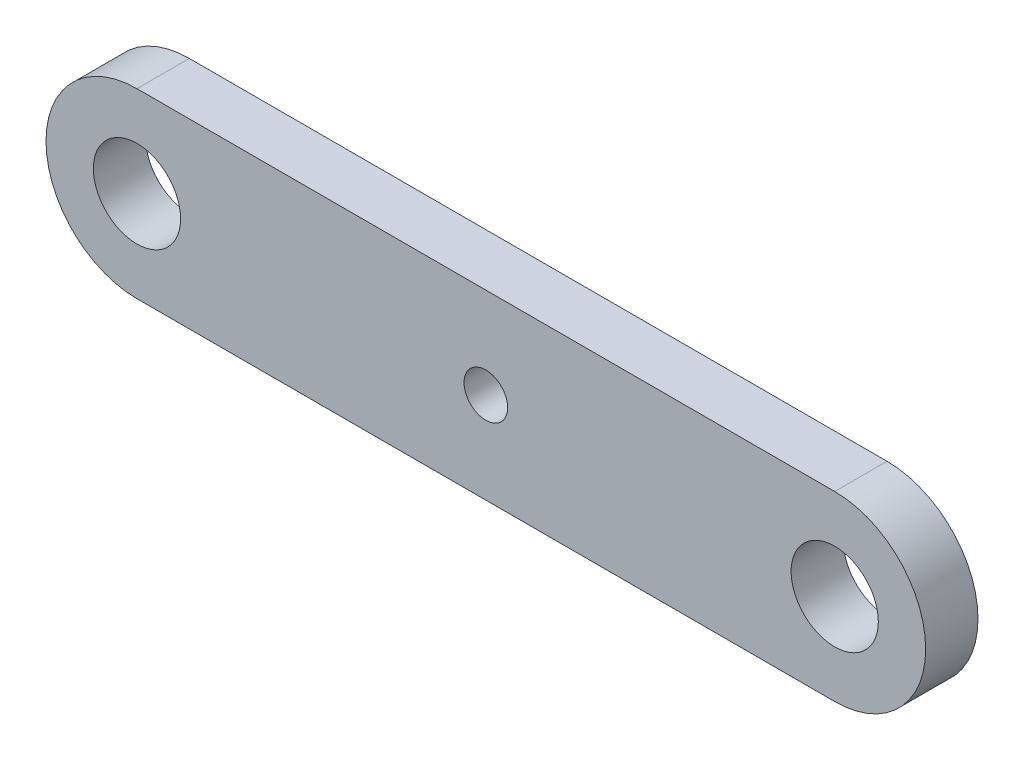
from build123d import *

# Parameters (mm, degrees)
CROQUIS1_R              = 5
CROQUIS1_R_2            = 2.5
SALIENTE_EXTRUIR1_DEPTH = 6


with BuildPart() as part:
    # Croquis1 → Saliente-Extruir1 (new body)
    with BuildSketch(Plane.XY):
        with BuildLine():
            Line((-42.03699633, 10.429447853), (37.96300367, 10.429447853))
            ThreePointArc((37.96300367, 10.429447853), (48.392451523, 0), (37.96300367, -10.429447853))
            Line((37.96300367, -10.429447853), (-42.03699633, -10.429447853))
            ThreePointArc((-42.03699633, -10.429447853), (-52.466444182, 0), (-42.03699633, 10.429447853))
        make_face()
        with Locations((-42.03699633, 0)):
            Circle(CROQUIS1_R, mode=Mode.SUBTRACT)
        with Locations((37.96300367, 0)):
            Circle(CROQUIS1_R, mode=Mode.SUBTRACT)
        with Locations((-2.03699633, 0)):
            Circle(CROQUIS1_R_2, mode=Mode.SUBTRACT)
    extrude(amount=SALIENTE_EXTRUIR1_DEPTH)


solid = part.part
